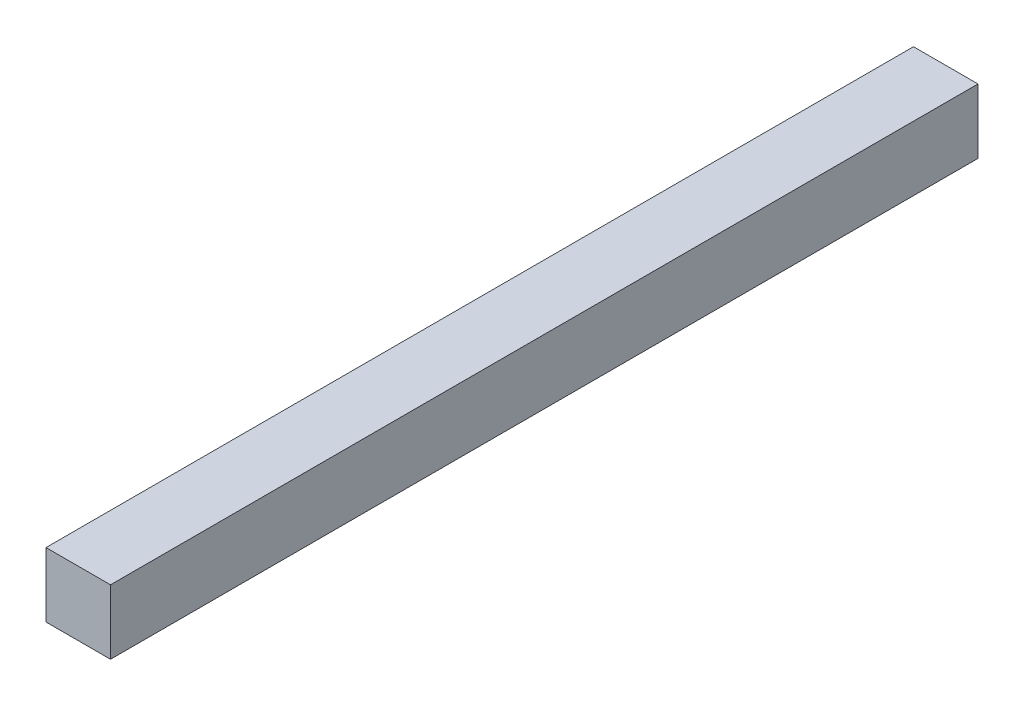
from build123d import *

# Parameters (mm, degrees)
SKETCH1_W           = 3.175
SKETCH1_H           = 3.175
BOSS_EXTRUDE1_DEPTH = 42.7


with BuildPart() as part:
    # Sketch1 → Boss-Extrude1 (new body)
    with BuildSketch(Plane.XY):
        with Locations((1.5875, 1.5875)):
            Rectangle(SKETCH1_W, SKETCH1_H)
    extrude(amount=BOSS_EXTRUDE1_DEPTH)


solid = part.part
